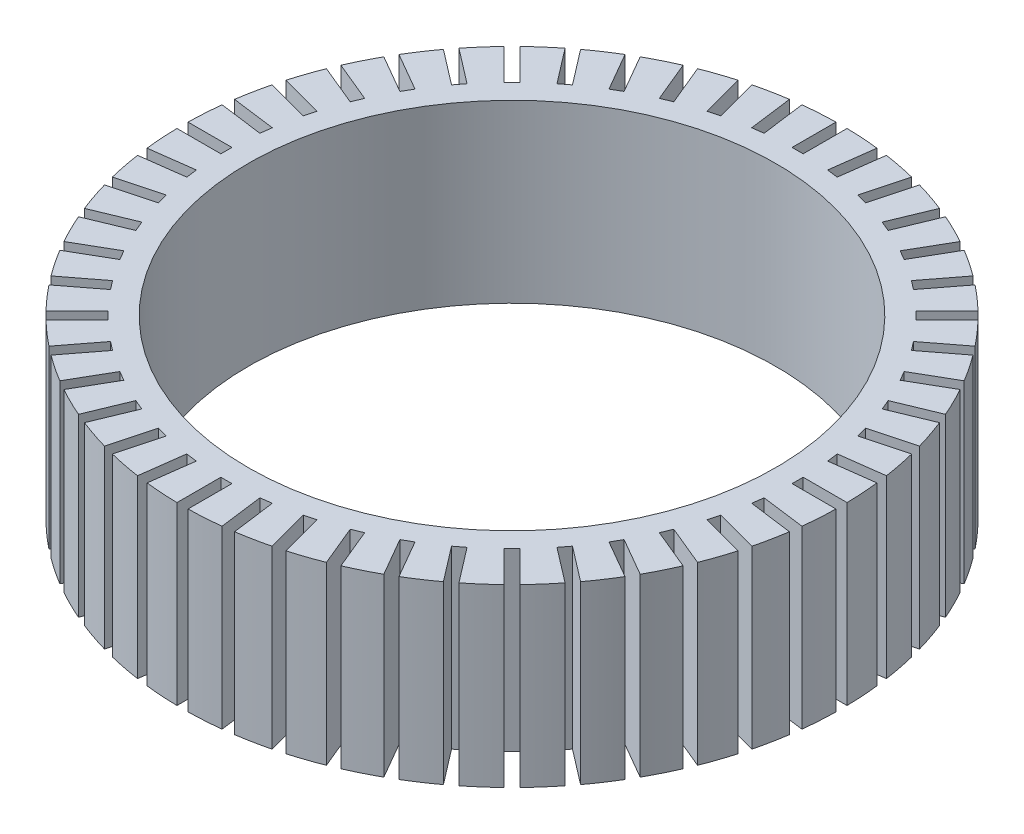
from build123d import *

# Parameters (mm, degrees)
SKETCH2_W          = 4.7625
SKETCH2_H          = 12.7
SKETCH3_W          = 25.4
SKETCH3_H          = 0.8001
CUT_EXTRUDE1_DEPTH = 12.7
CIRPATTERN1_COUNT  = 48


with BuildPart() as part:
    # Sketch2 → Revolve1 (revolve)
    with BuildSketch(Plane.XY):
        with Locations((-21.43125, 6.35)):
            Rectangle(SKETCH2_W, SKETCH2_H)
    revolve(axis=Axis((0, 80.4, 0), (0, -1, 0)))

    # Sketch3 → Cut-Extrude1 (cut)
    with BuildSketch(Plane(origin=(0, 0, 0), x_dir=(1, 0, 0), z_dir=(0, 1, 0))):
        with Locations((-33.3375, 0)):
            Rectangle(SKETCH3_W, SKETCH3_H)
    cut_extrude1 = extrude(amount=CUT_EXTRUDE1_DEPTH, mode=Mode.SUBTRACT)

    # CirPattern1: Cut-Extrude1 ×48 about axis
    cirpattern1_axis = Axis((0, 0, 0), (0, 1, 0))
    for i in range(1, CIRPATTERN1_COUNT):
        add(cut_extrude1.rotate(cirpattern1_axis, i * 360 / CIRPATTERN1_COUNT), mode=Mode.SUBTRACT)


solid = part.part
